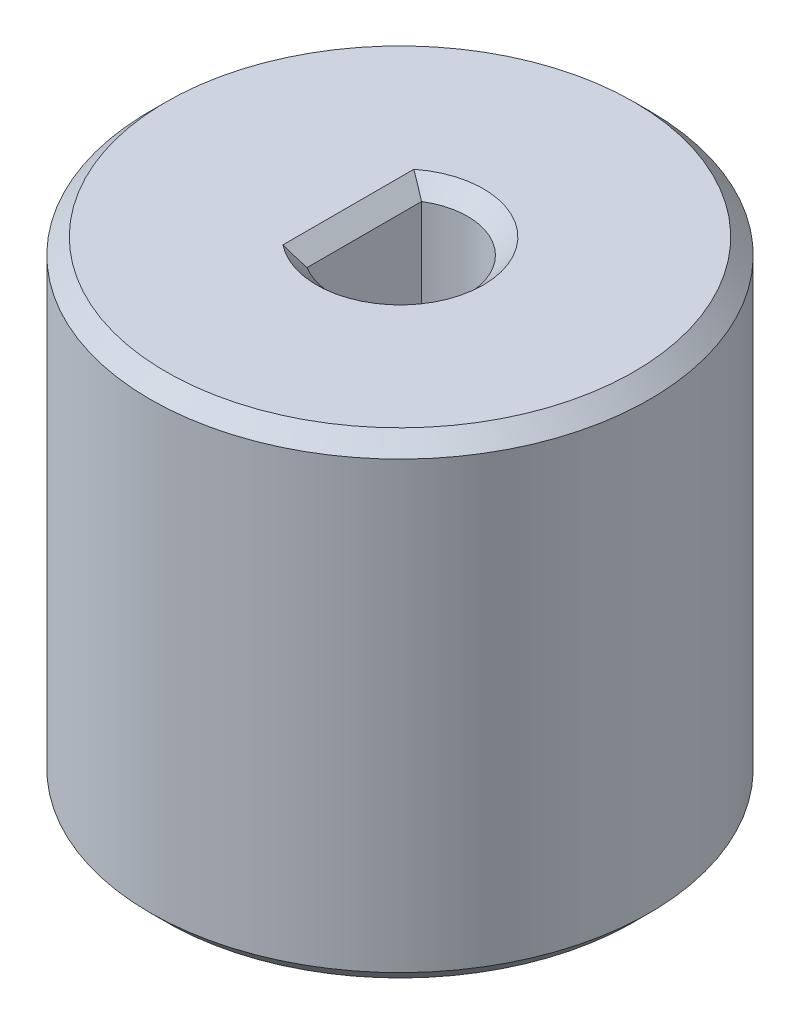
from build123d import *

# Parameters (mm, degrees)
CROQUIS3_W              = 4
CROQUIS3_H              = 7.21110255
SALIENTE_EXTRUIR1_DEPTH = 15
CHAFL_N1_SIZE           = 1


with BuildPart() as part:
    # Croquis2 → Revolución1 (revolve)
    with BuildSketch(Plane.XY):
        Polygon((-4.25, 30), (-14.725, 30), (-15.725, 29), (-15.725, 1), (-14.725, 0), (-13.725, 0), (-12.725, 1), (-12.725, 14), (-11.725, 15), (-4.25, 15), align=None)
    revolve(axis=Axis((0, 0, 0), (0, 1, 0)))

    # Croquis3 → Saliente-Extruir1 (add)
    with BuildSketch(Plane(origin=(0, 30, 0), x_dir=(1, 0, 0), z_dir=(0, 1, 0))):
        with Locations((-4.25, 0)):
            Rectangle(CROQUIS3_W, CROQUIS3_H)
    extrude(amount=-SALIENTE_EXTRUIR1_DEPTH)

    # Chaflán1
    chafl_n1_edges = [part.edges().sort_by_distance(p)[0] for p in [
        (4.25, 30, 0),
        (-2.25, 30, 0),
    ]]
    chamfer(chafl_n1_edges, length=CHAFL_N1_SIZE)


solid = part.part
